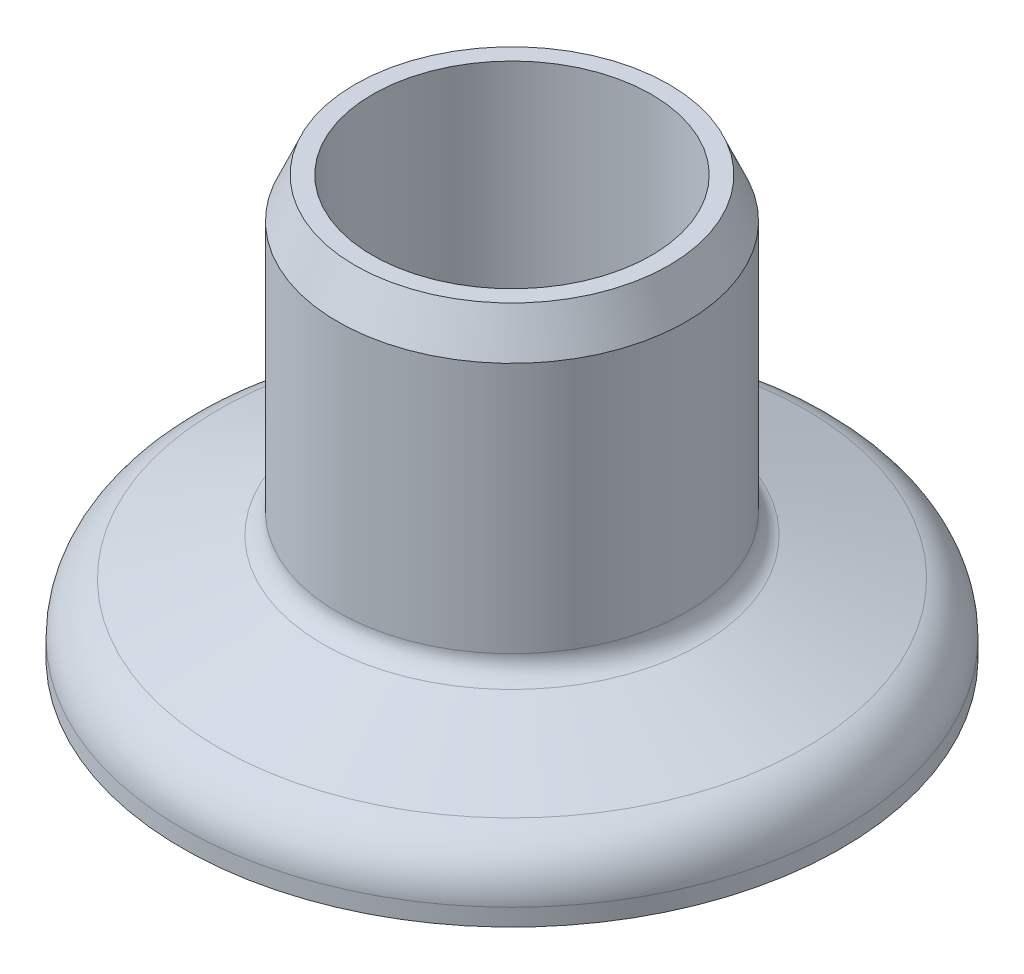
from build123d import *

# Parameters (mm, degrees)
FILLET1_R = 2.5
FILLET2_R = 1


with BuildPart() as part:
    # Sketch1 → Revolve1 (revolve)
    with BuildSketch(Plane.XY):
        Polygon((6.35, 19.05), (7.14375, 19.05), (7.9375, 17.231027131), (7.9375, 5.08), (15, 2.54), (15, 0), (6.35, 0), align=None)
    revolve(axis=Axis((0, -0.9525, 0), (0, 1, 0)))

    # Fillet1
    fillet1_edges = [part.edges().sort_by_distance(p)[0] for p in [
        (-15, 2.54, 0),
    ]]
    fillet(fillet1_edges, radius=FILLET1_R)

    # Fillet2
    fillet2_edges = [part.edges().sort_by_distance(p)[0] for p in [
        (-7.9375, 5.08, 0),
    ]]
    fillet(fillet2_edges, radius=FILLET2_R)


solid = part.part
